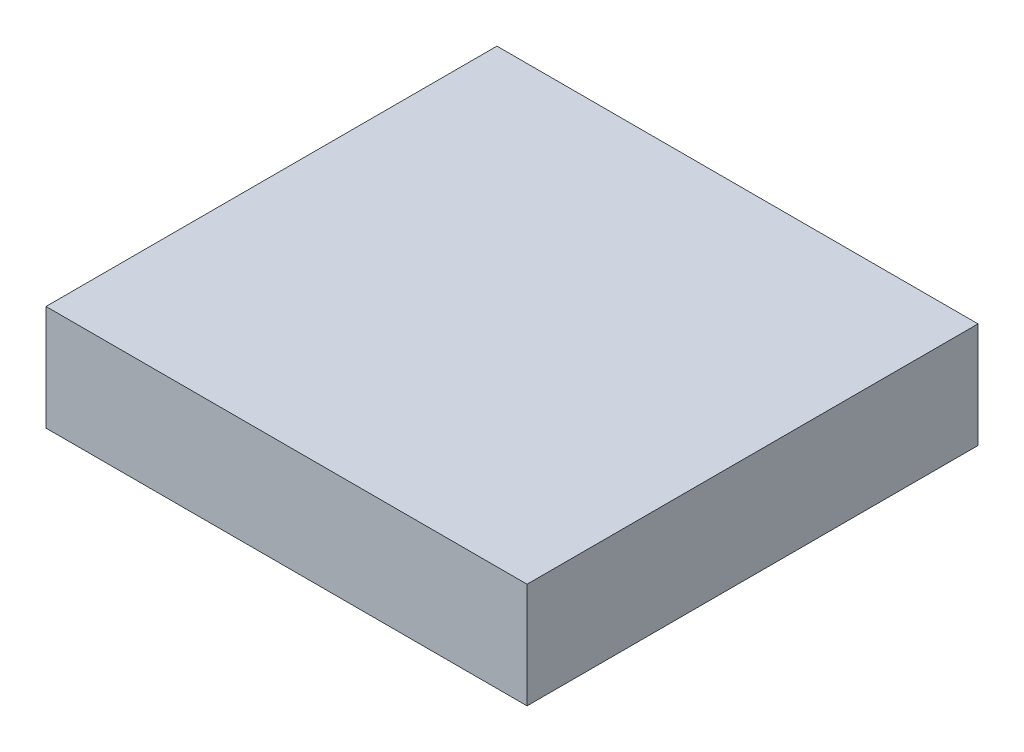
from build123d import *

# Parameters (mm, degrees)
SKETCH1_W           = 21.336
SKETCH1_H           = 20
BOSS_EXTRUDE1_DEPTH = 4.6736


with BuildPart() as part:
    # Sketch1 → Boss-Extrude1 (new body)
    with BuildSketch(Plane(origin=(0, 0, 0), x_dir=(1, 0, 0), z_dir=(0, 1, 0))):
        with Locations((10.668, 10)):
            Rectangle(SKETCH1_W, SKETCH1_H)
    extrude(amount=BOSS_EXTRUDE1_DEPTH)


solid = part.part
